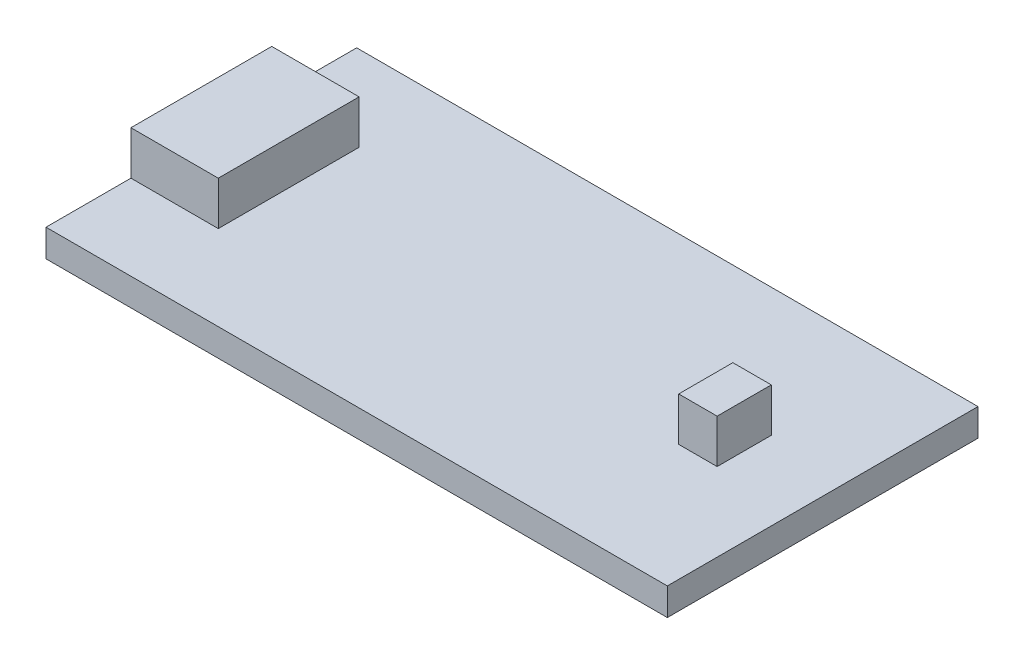
from build123d import *

# Parameters (mm, degrees)
SKETCH1_W           = 35.56
SKETCH1_H           = 17.78
BOARD_DEPTH         = 1.57
SKETCH2_W           = 5
SKETCH2_H           = 8.06
MICROUSB_DEPTH      = 2.5
SKETCH3_W           = 2.2
SKETCH3_H           = 3.1
BUTTON_DEPTH        = 2.5
SKETCH4_W           = 1.388748629
SKETCH4_H           = 1.080137823
SKETCH4_W_2         = 1.028702689
SKETCH4_H_2         = 1.234443227
SKETCH4_W_3         = 1.131572957
SKETCH4_H_3         = 1.594489167
SKETCH4_W_4         = 0.720091882
SKETCH4_H_4         = 2.468886452
SKETCH4_W_5         = 1.74879457
SKETCH4_H_5         = 1.85166484
SKETCH4_W_6         = 0.925832419
SKETCH4_H_6         = 2.441025755
SKETCH4_W_7         = 0.76580757
SKETCH4_H_7         = 1.866499914
SKETCH4_W_8         = 1.080137823
SKETCH4_H_8         = 1.748794571
BOSS_EXTRUDE1_DEPTH = 1


with BuildPart() as part:
    # Sketch1 → Board (new body)
    with BuildSketch(Plane(origin=(0, 0, 0), x_dir=(1, 0, 0), z_dir=(0, 1, 0))):
        Rectangle(SKETCH1_W, SKETCH1_H)
    extrude(amount=BOARD_DEPTH)

    # Sketch2 → MicroUSB (add)
    with BuildSketch(Plane(origin=(0, 1.57, 0), x_dir=(1, 0, 0), z_dir=(0, 1, 0))):
        with Locations((-15.28, 0)):
            Rectangle(SKETCH2_W, SKETCH2_H)
    extrude(amount=MICROUSB_DEPTH)

    # Sketch3 → Button (add)
    with BuildSketch(Plane(origin=(0, 1.57, 0), x_dir=(1, 0, 0), z_dir=(0, 1, 0))):
        with Locations((12.19, 0)):
            Rectangle(SKETCH3_W, SKETCH3_H)
    extrude(amount=BUTTON_DEPTH)

    # Sketch4 → Boss-Extrude1 (add)
    with BuildSketch(Plane(origin=(0, 0, 0), x_dir=(1, 0, 0), z_dir=(0, 1, 0))):
        with Locations((-3.317566171, 4.371986427)):
            Rectangle(SKETCH4_W, SKETCH4_H)
        with Locations((1.260160794, 3.214695902)):
            Rectangle(SKETCH4_W_2, SKETCH4_H_2)
        with Locations((4.809185068, 3.574741842)):
            Rectangle(SKETCH4_W_3, SKETCH4_H_3)
        with Locations((3.60045941, 0)):
            Rectangle(SKETCH4_W_4, SKETCH4_H_4)
        with Locations((0.257175672, -2.777497259)):
            Rectangle(SKETCH4_W_5, SKETCH4_H_5)
        with Locations((-3.317566171, -3.357214086)):
            Rectangle(SKETCH4_W_6, SKETCH4_H_6)
        with Locations((-2.32174824, 0.229771707)):
            Rectangle(SKETCH4_W_7, SKETCH4_H_7)
        with Locations((3.240413468, -3.703329679)):
            Rectangle(SKETCH4_W_8, SKETCH4_H_8)
    extrude(amount=-BOSS_EXTRUDE1_DEPTH)


solid = part.part
